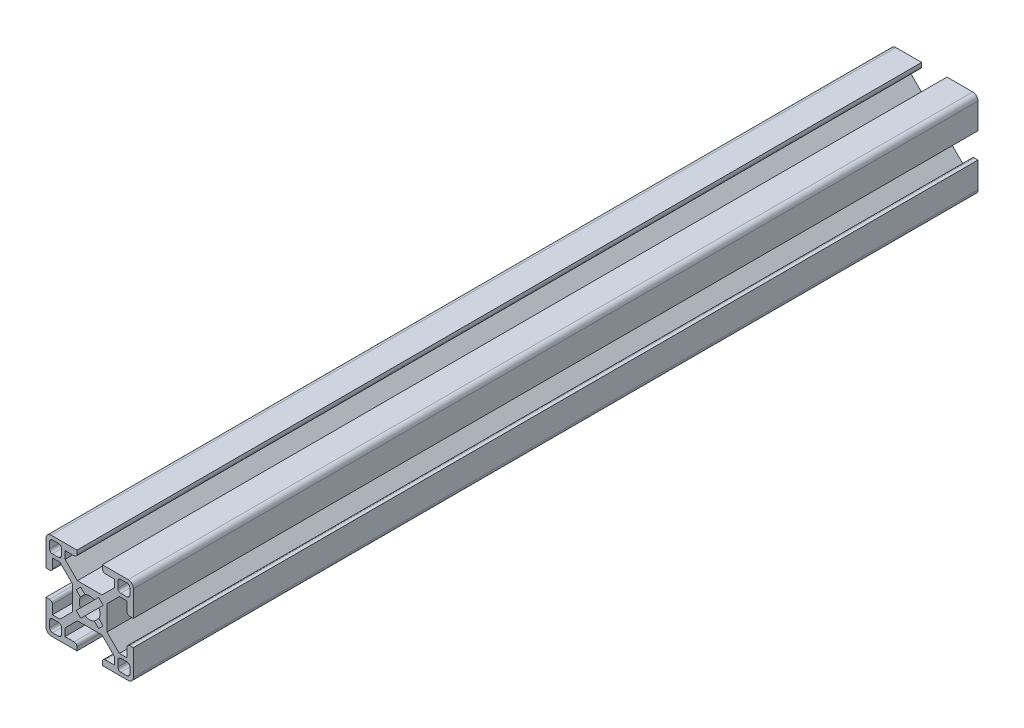
from build123d import *

# Parameters (mm, degrees)
SKETCH1_W           = 11.9
SKETCH1_H           = 5.95
BOSS_EXTRUDE1_DEPTH = 290
CUT_EXTRUDE1_DEPTH  = 291


with BuildPart() as part:
    # Sketch1 → Boss-Extrude1 (new body)
    with BuildSketch(Plane.XY):
        with BuildLine():
            Line((-4.350229073, 14.992640687), (-13.192640687, 14.992640687))
            ThreePointArc((-13.192640687, 14.992640687), (-14.465432893, 14.465432893), (-14.992640687, 13.192640687))
            Line((-14.992640687, 13.192640687), (-14.992640687, 4.350229073))
            Line((-14.992640687, 4.350229073), (-13.792640687, 4.350229073))
            ThreePointArc((-13.792640687, 4.350229073), (-13.085533906, 4.643122292), (-12.792640687, 5.350229073))
            Line((-12.792640687, 5.350229073), (-12.792640687, 8.460229073))
            Line((-12.792640687, 8.460229073), (-8.460229073, 8.460229073))
            Line((-8.460229073, 8.460229073), (-8.460229073, 12.792640687))
            Line((-8.460229073, 12.792640687), (-5.350229073, 12.792640687))
            ThreePointArc((-5.350229073, 12.792640687), (-4.643122292, 13.085533906), (-4.350229073, 13.792640687))
            Line((-4.350229073, 13.792640687), (-4.350229073, 14.992640687))
        make_face()
        with BuildLine():
            Line((-10.660229073, 13.792640687), (-12.792640687, 13.792640687))
            ThreePointArc((-12.792640687, 13.792640687), (-13.499747468, 13.499747468), (-13.792640687, 12.792640687))
            Line((-13.792640687, 12.792640687), (-13.792640687, 10.660229073))
            ThreePointArc((-13.792640687, 10.660229073), (-13.499747468, 9.953122292), (-12.792640687, 9.660229073))
            Line((-12.792640687, 9.660229073), (-10.660229073, 9.660229073))
            ThreePointArc((-10.660229073, 9.660229073), (-9.953122292, 9.953122292), (-9.660229073, 10.660229073))
            Line((-9.660229073, 10.660229073), (-9.660229073, 12.792640687))
            ThreePointArc((-9.660229073, 12.792640687), (-9.953122292, 13.499747468), (-10.660229073, 13.792640687))
        make_face(mode=Mode.SUBTRACT)
        Polygon((-5.95, 4.217588386), (-5.95, 5.95), (-4.217588386, 5.95), (-8.460229073, 10.192640687), (-8.460229073, 8.460229073), (-10.192640687, 8.460229073), align=None)
        with Locations((0, 2.975)):
            Rectangle(SKETCH1_W, SKETCH1_H)
        Polygon((8.460229073, 10.192640687), (4.217588386, 5.95), (5.95, 5.95), (5.95, 4.217588386), (10.192640687, 8.460229073), (8.460229073, 8.460229073), align=None)
        with BuildLine():
            Line((12.792640687, 8.460229073), (12.792640687, 5.350229073))
            ThreePointArc((12.792640687, 5.350229073), (13.085533906, 4.643122292), (13.792640687, 4.350229073))
            Line((13.792640687, 4.350229073), (14.992640687, 4.350229073))
            Line((14.992640687, 4.350229073), (14.992640687, 13.192640687))
            ThreePointArc((14.992640687, 13.192640687), (14.465432893, 14.465432893), (13.192640687, 14.992640687))
            Line((13.192640687, 14.992640687), (4.350229073, 14.992640687))
            Line((4.350229073, 14.992640687), (4.350229073, 13.792640687))
            ThreePointArc((4.350229073, 13.792640687), (4.643122292, 13.085533906), (5.350229073, 12.792640687))
            Line((5.350229073, 12.792640687), (8.460229073, 12.792640687))
            Line((8.460229073, 12.792640687), (8.460229073, 8.460229073))
            Line((8.460229073, 8.460229073), (12.792640687, 8.460229073))
        make_face()
        with BuildLine():
            ThreePointArc((9.660229073, 10.660229073), (9.953122292, 9.953122292), (10.660229073, 9.660229073))
            Line((10.660229073, 9.660229073), (12.792640687, 9.660229073))
            ThreePointArc((12.792640687, 9.660229073), (13.499747468, 9.953122292), (13.792640687, 10.660229073))
            Line((13.792640687, 10.660229073), (13.792640687, 12.792640687))
            ThreePointArc((13.792640687, 12.792640687), (13.499747468, 13.499747468), (12.792640687, 13.792640687))
            Line((12.792640687, 13.792640687), (10.660229073, 13.792640687))
            ThreePointArc((10.660229073, 13.792640687), (9.953122292, 13.499747468), (9.660229073, 12.792640687))
            Line((9.660229073, 12.792640687), (9.660229073, 10.660229073))
        make_face(mode=Mode.SUBTRACT)
    extrude(amount=-BOSS_EXTRUDE1_DEPTH)

    # Mirror1: part across plane


with BuildPart() as part_1:
    add(part.part)
    add(part.part.mirror(Plane(origin=(0, 0, -290), x_dir=(0, 0, 1), z_dir=(0, -1, 0))))

    # Sketch2 → Cut-Extrude1 (cut, through all)
    with BuildSketch(Plane.XY):
        with BuildLine():
            Line((-4.631549417, 3.075914498), (-3.16821753, 1.612582612))
            ThreePointArc((-3.16821753, 1.612582612), (-2.513764607, 2.513764607), (-1.612582612, 3.16821753))
            Line((-1.612582612, 3.16821753), (-3.075914498, 4.631549417))
            Line((-3.075914498, 4.631549417), (-4.631549417, 3.075914498))
        make_face()
        with BuildLine():
            Line((-3.16821753, 1.612582612), (-1.555634919, 0))
            Line((-1.555634919, 0), (0, 1.555634919))
            Line((0, 1.555634919), (-1.612582612, 3.16821753))
            ThreePointArc((-1.612582612, 3.16821753), (-2.513764607, 2.513764607), (-3.16821753, 1.612582612))
        make_face()
        with BuildLine():
            ThreePointArc((-3.16821753, 1.612582612), (-3.555, 0), (-3.16821753, -1.612582612))
            Line((-3.16821753, -1.612582612), (-1.555634919, 0))
            Line((-1.555634919, 0), (-3.16821753, 1.612582612))
        make_face()
        with BuildLine():
            Line((-4.631549417, -3.075914498), (-3.075914498, -4.631549417))
            Line((-3.075914498, -4.631549417), (-1.612582612, -3.16821753))
            ThreePointArc((-1.612582612, -3.16821753), (-2.513764607, -2.513764607), (-3.16821753, -1.612582612))
            Line((-3.16821753, -1.612582612), (-4.631549417, -3.075914498))
        make_face()
        with BuildLine():
            ThreePointArc((-3.16821753, -1.612582612), (-2.513764607, -2.513764607), (-1.612582612, -3.16821753))
            Line((-1.612582612, -3.16821753), (0, -1.555634919))
            Line((0, -1.555634919), (-1.555634919, 0))
            Line((-1.555634919, 0), (-3.16821753, -1.612582612))
        make_face()
        with BuildLine():
            Line((0, -1.555634919), (-1.612582612, -3.16821753))
            ThreePointArc((-1.612582612, -3.16821753), (0, -3.555), (1.612582612, -3.16821753))
            Line((1.612582612, -3.16821753), (0, -1.555634919))
        make_face()
        with BuildLine():
            Line((1.555634919, 0), (0, -1.555634919))
            Line((0, -1.555634919), (1.612582612, -3.16821753))
            ThreePointArc((1.612582612, -3.16821753), (2.513764607, -2.513764607), (3.16821753, -1.612582612))
            Line((3.16821753, -1.612582612), (1.555634919, 0))
        make_face()
        with BuildLine():
            Line((3.16821753, 1.612582612), (1.555634919, 0))
            Line((1.555634919, 0), (3.16821753, -1.612582612))
            ThreePointArc((3.16821753, -1.612582612), (3.456952294, -0.829159719), (3.555, 0))
            ThreePointArc((3.555, 0), (3.456952294, 0.829159719), (3.16821753, 1.612582612))
        make_face()
        Polygon((-1.555634919, 0), (0, -1.555634919), (1.555634919, 0), (0, 1.555634919), align=None)
        with BuildLine():
            Line((0, 1.555634919), (1.555634919, 0))
            Line((1.555634919, 0), (3.16821753, 1.612582612))
            ThreePointArc((3.16821753, 1.612582612), (2.513764607, 2.513764607), (1.612582612, 3.16821753))
            Line((1.612582612, 3.16821753), (0, 1.555634919))
        make_face()
        with BuildLine():
            Line((-1.612582612, 3.16821753), (0, 1.555634919))
            Line((0, 1.555634919), (1.612582612, 3.16821753))
            ThreePointArc((1.612582612, 3.16821753), (0, 3.555), (-1.612582612, 3.16821753))
        make_face()
        with BuildLine():
            ThreePointArc((1.612582612, 3.16821753), (2.513764607, 2.513764607), (3.16821753, 1.612582612))
            Line((3.16821753, 1.612582612), (4.631549417, 3.075914498))
            Line((4.631549417, 3.075914498), (3.075914498, 4.631549417))
            Line((3.075914498, 4.631549417), (1.612582612, 3.16821753))
        make_face()
        with BuildLine():
            ThreePointArc((3.16821753, -1.612582612), (2.513764607, -2.513764607), (1.612582612, -3.16821753))
            Line((1.612582612, -3.16821753), (3.075914498, -4.631549417))
            Line((3.075914498, -4.631549417), (4.631549417, -3.075914498))
            Line((4.631549417, -3.075914498), (3.16821753, -1.612582612))
        make_face()
    extrude(amount=-CUT_EXTRUDE1_DEPTH, mode=Mode.SUBTRACT)


solid = part_1.part
